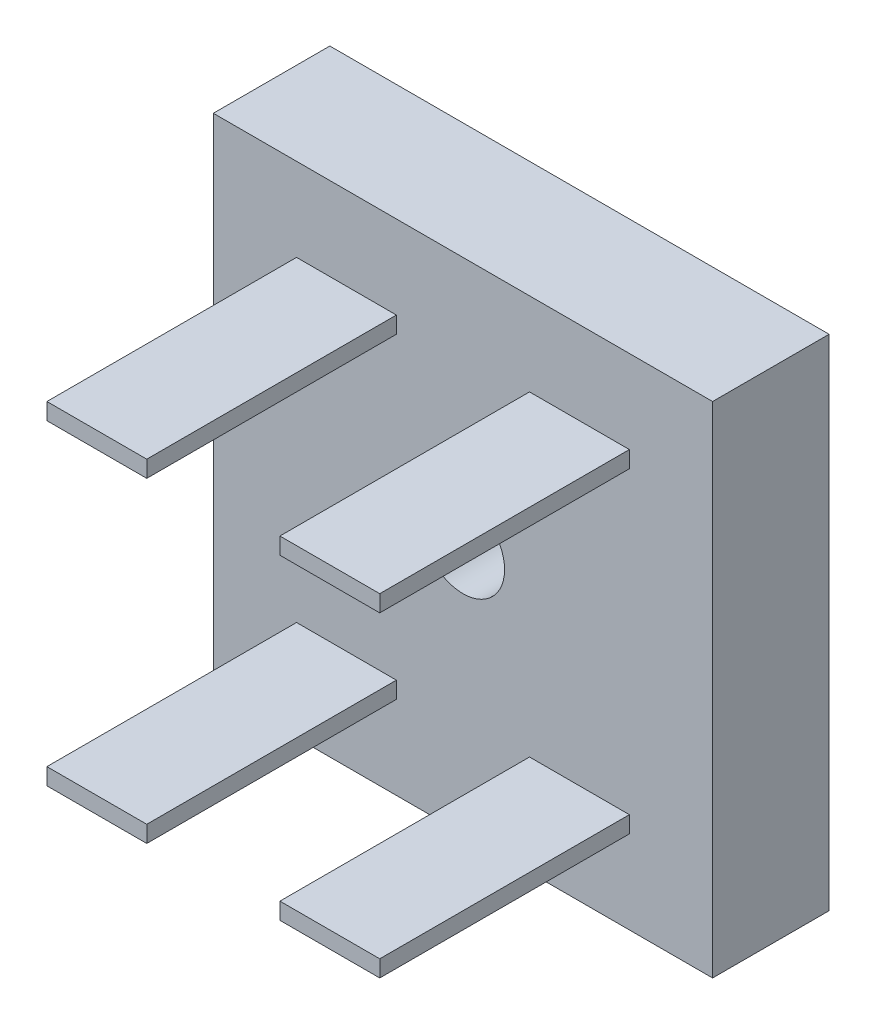
from build123d import *

# Parameters (mm, degrees)
ESQUISSE1_W        = 30
ESQUISSE1_H        = 30
ESQUISSE1_R        = 2.5
BOSS_EXTRU_1_DEPTH = 7
ESQUISSE2_W        = 6
ESQUISSE2_H        = 1
BOSS_EXTRU_2_DEPTH = 15


with BuildPart() as part:
    # Esquisse1 → Boss.-Extru.1 (new body)
    with BuildSketch(Plane.XY):
        with Locations((11.780048077, -12.282786885)):
            Rectangle(ESQUISSE1_W, ESQUISSE1_H)
        with Locations((11.780048077, -12.282786885)):
            Circle(ESQUISSE1_R, mode=Mode.SUBTRACT)
    extrude(amount=BOSS_EXTRU_1_DEPTH)

    # Esquisse2 → Boss.-Extru.2 (add)
    with BuildSketch(Plane.XY.offset(7)):
        with Locations((4.780048077, -2.782786885)):
            Rectangle(ESQUISSE2_W, ESQUISSE2_H)
        with Locations((18.780048077, -2.782786885)):
            Rectangle(ESQUISSE2_W, ESQUISSE2_H)
        with Locations((4.780048077, -21.782786885)):
            Rectangle(ESQUISSE2_W, ESQUISSE2_H)
        with Locations((18.780048077, -21.782786885)):
            Rectangle(ESQUISSE2_W, ESQUISSE2_H)
    extrude(amount=BOSS_EXTRU_2_DEPTH)


solid = part.part
